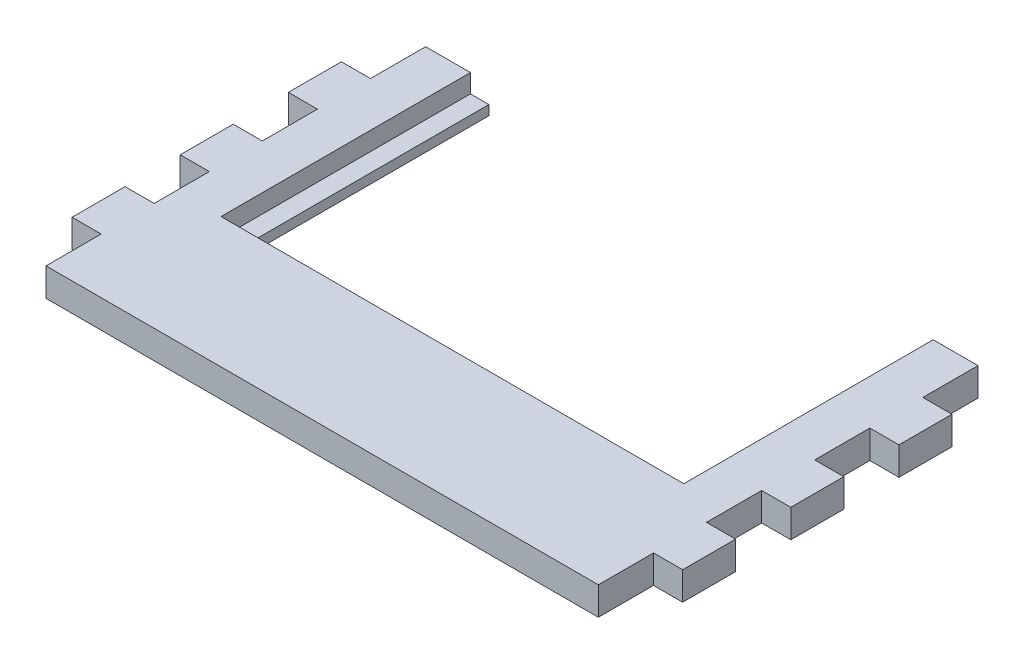
from build123d import *

# Parameters (mm, degrees)
BOSS_EXTRU_1_DEPTH      = 15.25
ESQUISSE2_W             = 250.5
ESQUISSE2_H             = 135
ENL_V_MAT_EXTRU_1_DEPTH = 10
ESQUISSE3_W             = 15.75
ESQUISSE3_H             = 29.857142857
ESQUISSE3_H_2           = 29.857142858
ENL_V_MAT_EXTRU_2_DEPTH = 15.25


with BuildPart() as part:
    # Esquisse1 → Boss.-Extru.1 (new body)
    with BuildSketch(Plane(origin=(0, 0, 0), x_dir=(1, 0, 0), z_dir=(0, 1, 0))):
        Polygon((-113.085152838, 185.313864629), (-163.085152838, 185.313864629), (-163.085152838, -20.186135371), (167.414847162, -20.186135371), (167.414847162, 185.313864629), (117.414847162, 185.313864629), (117.414847162, 60.313864629), (-113.085152838, 60.313864629), align=None)
    extrude(amount=BOSS_EXTRU_1_DEPTH)

    # Esquisse2 → Enlèv. mat.-Extru.1 (cut)
    with BuildSketch(Plane(origin=(0, 15.25, 0), x_dir=(1, 0, 0), z_dir=(0, 1, 0))):
        with Locations((2.164847162, 117.813864629)):
            Rectangle(ESQUISSE2_W, ESQUISSE2_H)
    extrude(amount=-ENL_V_MAT_EXTRU_1_DEPTH, mode=Mode.SUBTRACT)

    # Esquisse3 → Enlèv. mat.-Extru.2 (cut)
    with BuildSketch(Plane(origin=(0, 15.25, 0), x_dir=(1, 0, 0), z_dir=(0, 1, 0))):
        with Locations((-155.210152838, 170.385293201)):
            Rectangle(ESQUISSE3_W, ESQUISSE3_H)
        with Locations((-155.210152838, 111.837674152)):
            Rectangle(ESQUISSE3_W, ESQUISSE3_H)
        with Locations((-155.210152838, 53.290055105)):
            Rectangle(ESQUISSE3_W, ESQUISSE3_H_2)
        with Locations((-155.210152838, -5.257563943)):
            Rectangle(ESQUISSE3_W, ESQUISSE3_H)
    enl_v_mat_extru_2 = extrude(amount=-ENL_V_MAT_EXTRU_2_DEPTH, mode=Mode.SUBTRACT)

    # Symétrie1: Enlèv. mat.-Extru.2 across plane
    add(enl_v_mat_extru_2.mirror(Plane.ZY.offset(-2.164847162)), mode=Mode.SUBTRACT)


solid = part.part
